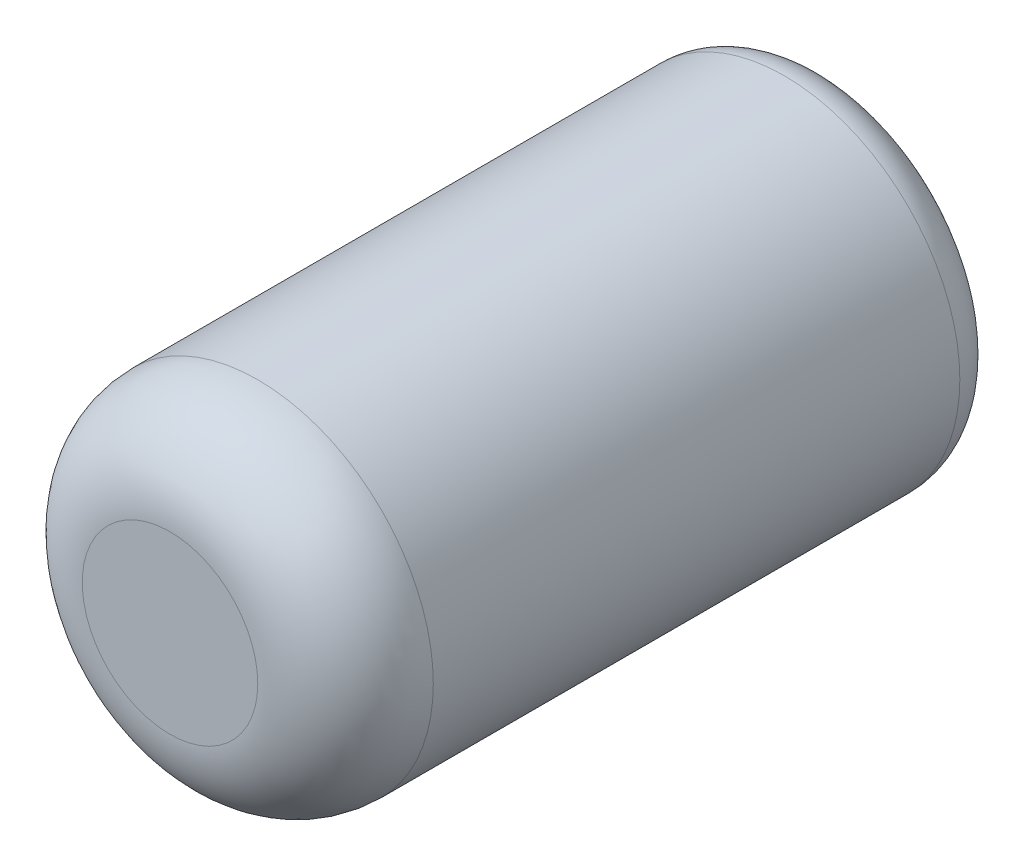
from build123d import *

# Parameters (mm, degrees)
SKIZZE1_R                       = 4
AUFSATZ_LINEAR_AUSTRAGEN1_DEPTH = 15
VERRUNDUNG1_R                   = 2
VERRUNDUNG2_R                   = 1


with BuildPart() as part:
    # Skizze1 → Aufsatz-Linear austragen1 (new body)
    with BuildSketch(Plane.XY):
        Circle(SKIZZE1_R)
    extrude(amount=AUFSATZ_LINEAR_AUSTRAGEN1_DEPTH)

    # Verrundung1
    verrundung1_edges = [part.edges().sort_by_distance(p)[0] for p in [
        (-4, 0, 15),
    ]]
    fillet(verrundung1_edges, radius=VERRUNDUNG1_R)

    # Verrundung2
    verrundung2_edges = [part.edges().sort_by_distance(p)[0] for p in [
        (-4, 0, 0),
    ]]
    fillet(verrundung2_edges, radius=VERRUNDUNG2_R)


solid = part.part
